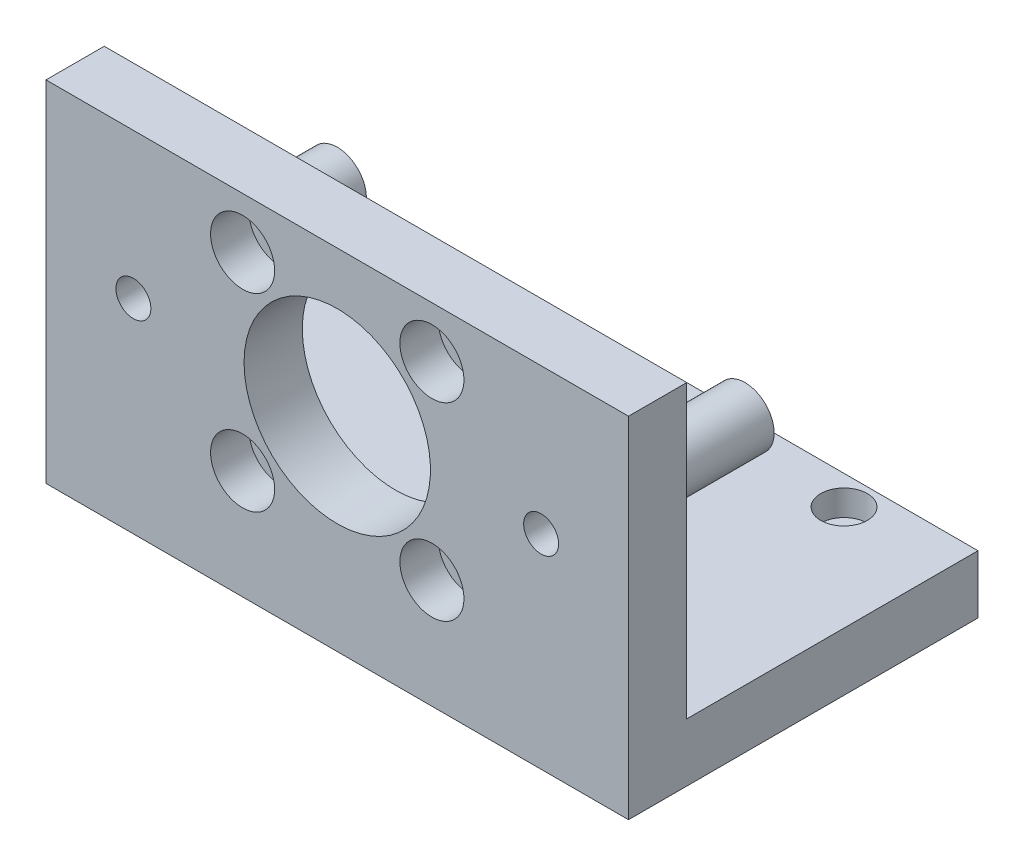
from build123d import *

# Parameters (mm, degrees)
SKETCH1_W           = 100
SKETCH1_H           = 50
BOSS_EXTRUDE1_DEPTH = 10
SKETCH2_R           = 2.25
CUT_EXTRUDE1_DEPTH  = 11
SKETCH3_R           = 4
CUT_EXTRUDE2_DEPTH  = 4.4
SKETCH4_W           = 100
SKETCH4_H           = 60
BOSS_EXTRUDE2_DEPTH = 10
SKETCH5_R           = 16
CUT_EXTRUDE3_DEPTH  = 11
SKETCH6_R           = 3.3
CUT_EXTRUDE4_DEPTH  = 11
SKETCH7_R           = 5.5
CUT_EXTRUDE5_DEPTH  = 6.6
SKETCH8_R           = 3
CUT_EXTRUDE6_DEPTH  = 11
SKETCH9_R           = 5
SKETCH9_R_2         = 3
BOSS_EXTRUDE3_DEPTH = 25


with BuildPart() as part:
    # Sketch1 → Boss-Extrude1 (new body)
    with BuildSketch(Plane(origin=(0, 0, 0), x_dir=(1, 0, 0), z_dir=(0, 1, 0))):
        Rectangle(SKETCH1_W, SKETCH1_H)
    extrude(amount=BOSS_EXTRUDE1_DEPTH)

    # Sketch2 → Cut-Extrude1 (cut, through all)
    with BuildSketch(Plane(origin=(0, 10, 0), x_dir=(1, 0, 0), z_dir=(0, 1, 0))):
        with Locations((32, 20)):
            Circle(SKETCH2_R)
        with Locations((32, -20)):
            Circle(SKETCH2_R)
        with Locations((-32, 20)):
            Circle(SKETCH2_R)
        with Locations((-32, -20)):
            Circle(SKETCH2_R)
    extrude(amount=-CUT_EXTRUDE1_DEPTH, mode=Mode.SUBTRACT)

    # Sketch3 → Cut-Extrude2 (cut)
    with BuildSketch(Plane(origin=(0, 10, 0), x_dir=(1, 0, 0), z_dir=(0, 1, 0))):
        with Locations((32, 20)):
            Circle(SKETCH3_R)
        with Locations((32, -20)):
            Circle(SKETCH3_R)
        with Locations((-32, 20)):
            Circle(SKETCH3_R)
        with Locations((-32, -20)):
            Circle(SKETCH3_R)
    extrude(amount=-CUT_EXTRUDE2_DEPTH, mode=Mode.SUBTRACT)

    # Sketch4 → Boss-Extrude2 (add)
    with BuildSketch(Plane.XY.offset(25)):
        with Locations((0, 30)):
            Rectangle(SKETCH4_W, SKETCH4_H)
    extrude(amount=BOSS_EXTRUDE2_DEPTH)

    # Sketch5 → Cut-Extrude3 (cut, through all)
    with BuildSketch(Plane(origin=(0, 0, 25), x_dir=(-1, 0, 0), z_dir=(0, 0, -1))):
        with Locations((0, 35)):
            Circle(SKETCH5_R)
    extrude(amount=-CUT_EXTRUDE3_DEPTH, mode=Mode.SUBTRACT)

    # Sketch6 → Cut-Extrude4 (cut, through all)
    with BuildSketch(Plane(origin=(0, 0, 25), x_dir=(-1, 0, 0), z_dir=(0, 0, -1))):
        with Locations((-16.25, 51.25)):
            Circle(SKETCH6_R)
        with Locations((-16.25, 18.75)):
            Circle(SKETCH6_R)
        with Locations((16.25, 18.75)):
            Circle(SKETCH6_R)
        with Locations((16.25, 51.25)):
            Circle(SKETCH6_R)
    extrude(amount=-CUT_EXTRUDE4_DEPTH, mode=Mode.SUBTRACT)

    # Sketch7 → Cut-Extrude5 (cut)
    with BuildSketch(Plane.XY.offset(35)):
        with Locations((-16.25, 51.25)):
            Circle(SKETCH7_R)
        with Locations((16.25, 51.25)):
            Circle(SKETCH7_R)
        with Locations((16.25, 18.75)):
            Circle(SKETCH7_R)
        with Locations((-16.25, 18.75)):
            Circle(SKETCH7_R)
    extrude(amount=-CUT_EXTRUDE5_DEPTH, mode=Mode.SUBTRACT)

    # Sketch8 → Cut-Extrude6 (cut, through all)
    with BuildSketch(Plane(origin=(0, 0, 25), x_dir=(-1, 0, 0), z_dir=(0, 0, -1))):
        with Locations((-35, 35)):
            Circle(SKETCH8_R)
        with Locations((35, 35)):
            Circle(SKETCH8_R)
    extrude(amount=-CUT_EXTRUDE6_DEPTH, mode=Mode.SUBTRACT)

    # Sketch9 → Boss-Extrude3 (add)
    with BuildSketch(Plane(origin=(0, 0, 25), x_dir=(-1, 0, 0), z_dir=(0, 0, -1))):
        with Locations((-35, 35)):
            Circle(SKETCH9_R)
        with Locations((-35, 35)):
            Circle(SKETCH9_R_2, mode=Mode.SUBTRACT)
        with Locations((35, 35)):
            Circle(SKETCH9_R)
        with Locations((35, 35)):
            Circle(SKETCH9_R_2, mode=Mode.SUBTRACT)
    extrude(amount=BOSS_EXTRUDE3_DEPTH)


solid = part.part
